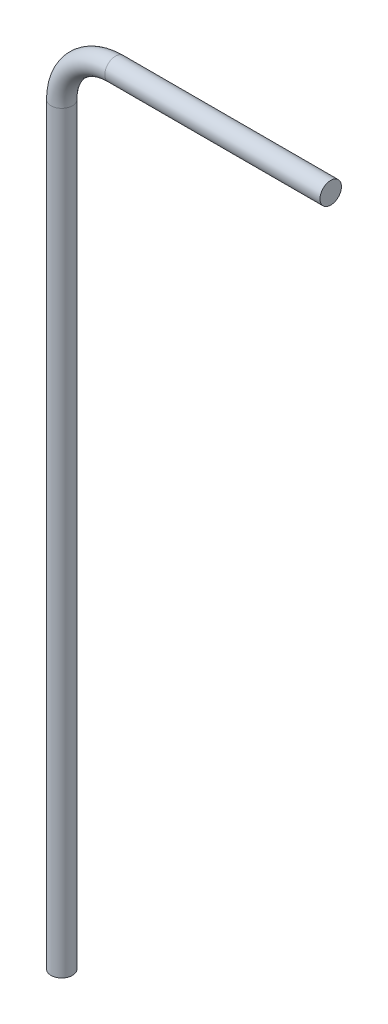
from build123d import *

# Parameters (mm, degrees)
SKETCH2_R = 2


with BuildPart() as part:
    # Sweep1: sweep along a path in Sketch1
    with BuildLine(Plane.XY) as sweep1_path:
        Line((0, -89.069234239), (0, 50.930765761))
        ThreePointArc((0, 50.930765761), (2.928932188, 58.001833573), (10, 60.930765761))
        Line((10, 60.930765761), (50, 60.930765761))
    # Sketch2 → Sweep1 (sweep)
    with BuildSketch(Plane(origin=(50, 0, 0), x_dir=(0, 0, -1), z_dir=(1, 0, 0))):
        with Locations((0, 60.930765761)):
            Circle(SKETCH2_R)
    sweep(path=sweep1_path.line)


solid = part.part
